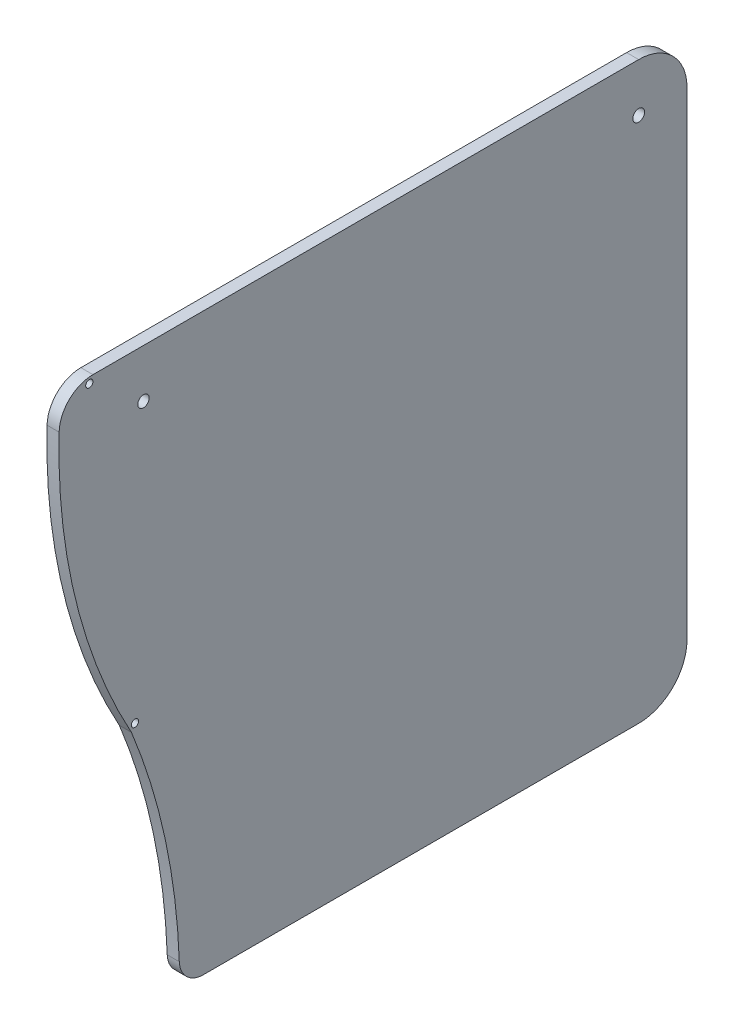
from build123d import *

# Parameters (mm, degrees)
SKETCH1_R           = 1.55
BOSS_EXTRUDE1_DEPTH = 3.175
CUT_EXTRUDE1_DEPTH  = 4.175
FILLET1_R           = 8.89
SKETCH3_R           = 1.5
CUT_EXTRUDE2_DEPTH  = 4.175
SKETCH4_R           = 0.9525
CUT_EXTRUDE3_DEPTH  = 4.175
FILLET2_R           = 6.35


with BuildPart() as part:
    # Sketch1 → Boss-Extrude1 (new body)
    with BuildSketch(Plane(origin=(0, 0, 0), x_dir=(0, 0, -1), z_dir=(1, 0, 0))):
        with BuildLine():
            Line((69.85, 75.565), (-82.55, 75.565))
            Line((-82.55, 75.565), (-82.55, -75.565))
            Line((-82.55, -75.565), (69.85, -75.565))
            ThreePointArc((69.85, -75.565), (78.830256121, -71.845256121), (82.55, -62.865))
            Line((82.55, -62.865), (82.55, 62.865))
            ThreePointArc((82.55, 62.865), (78.830256121, 71.845256121), (69.85, 75.565))
        make_face()
        with Locations((69.85, 62.865)):
            Circle(SKETCH1_R, mode=Mode.SUBTRACT)
    extrude(amount=BOSS_EXTRUDE1_DEPTH)

    # Sketch2 → Cut-Extrude1 (cut, through all)
    with BuildSketch(Plane(origin=(3.175, 0, 0), x_dir=(0, 0, -1), z_dir=(1, 0, 0))):
        with BuildLine():
            Line((-63.5, -10.915332745), (-63.5, -75.565))
            Line((-63.5, -75.565), (-50.8, -75.565))
            ThreePointArc((-50.8, -75.565), (-54.005053677, -42.622362446), (-63.5, -10.915332745))
        make_face()
        with BuildLine():
            Line((-82.55, 75.565), (-82.55, 62.865))
            ThreePointArc((-82.55, 62.865), (-82.417420191, 69.220528969), (-82.019911437, 75.565))
            Line((-82.019911437, 75.565), (-82.55, 75.565))
        make_face()
        with BuildLine():
            Line((-82.55, -75.565), (-63.5, -75.565))
            Line((-63.5, -75.565), (-63.5, -10.915332745))
            ThreePointArc((-63.5, -10.915332745), (-77.710665491, 24.765), (-82.55, 62.865))
            Line((-82.55, 62.865), (-82.55, -75.565))
        make_face()
    extrude(amount=-CUT_EXTRUDE1_DEPTH, mode=Mode.SUBTRACT)

    # Fillet1
    fillet1_edges = [part.edges().sort_by_distance(p)[0] for p in [
        (1.5875, 75.565, 82.019911437),
    ]]
    fillet(fillet1_edges, radius=FILLET1_R)

    # Sketch3 → Cut-Extrude2 (cut, through all)
    with BuildSketch(Plane(origin=(3.175, 0, 0), x_dir=(0, 0, -1), z_dir=(1, 0, 0))):
        with Locations((-60.325, 62.865)):
            Circle(SKETCH3_R)
    extrude(amount=-CUT_EXTRUDE2_DEPTH, mode=Mode.SUBTRACT)

    # Sketch4 → Cut-Extrude3 (cut, through all)
    with BuildSketch(Plane(origin=(3.175, 0, 0), x_dir=(0, 0, -1), z_dir=(1, 0, 0))):
        with Locations((-74.561915864, 73.9775)):
            Circle(SKETCH4_R)
        with Locations((-62.57206458, -9.313350112)):
            Circle(SKETCH4_R)
    extrude(amount=-CUT_EXTRUDE3_DEPTH, mode=Mode.SUBTRACT)

    # Fillet2
    fillet2_edges = [part.edges().sort_by_distance(p)[0] for p in [
        (1.5875, -75.565, 50.8),
    ]]
    fillet(fillet2_edges, radius=FILLET2_R)


solid = part.part
